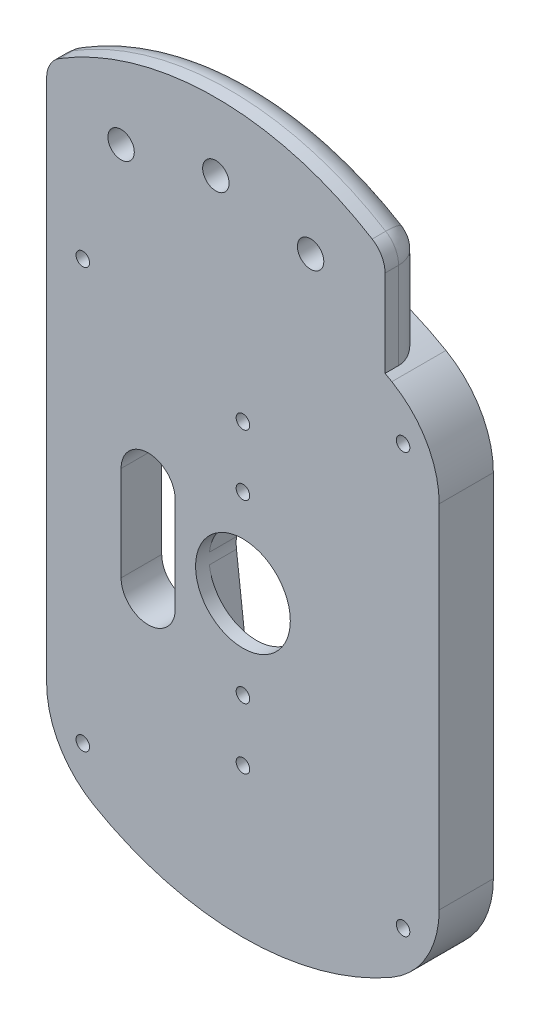
from build123d import *

# Parameters (mm, degrees)
EXTRUDE_1_DEPTH         = 6
SKETCH_1_3_R            = 1.0000000000000007
SKETCH_1_3_R_2          = 1.0000000000000009
EXTRUDE_2_DEPTH         = 2
SKETCH_1_4_R            = 1.0000000000000024
SKETCH_1_4_R_2          = 1.0000000000000022
SKETCH_1_4_R_3          = 0.9999999999999966
SKETCH_1_4_R_4          = 1.0000000000000009
EXTRUDE_3_DEPTH         = 8
CUT_EXTRUDE_1_DEPTH     = 54.0377224247045
EXTRUDE_4_DEPTH         = 6
FILLET_2_R              = 4
HOLE_WIZARD_M3_51_D     = 3.9
HOLE_WIZARD_M3_51_DEPTH = 13.828321793
HOLE_WIZARD_M3_51_TIP   = 1.1716782071037426


with BuildPart() as part:
    # Эскиз1 → Бобышка-Вытянуть1 (new body)
    with BuildSketch(Plane.XY):
        with BuildLine():
            Line((25.000000000000007, -25.98076211353316), (25.000000000000007, 25.980762113533153))
            ThreePointArc((25.000000000000007, 25.980762113533153), (24.981739705342804, 26.584808845817278), (24.927025509043382, 27.186649563837758))
            ThreePointArc((24.927025509043485, 27.18664956383775), (20.196152422706675, 28.98076211353309), (21.007841920590277, 33.974874663228555))
            ThreePointArc((21.007841920590295, 33.97487466322859), (20.513989667902422, 34.32317890618177), (20.000000000000014, 34.64101615137754))
            ThreePointArc((20.000000000000014, 34.64101615137754), (0, 40.00000000000001), (-20.000000000000018, 34.64101615137754))
            ThreePointArc((-20.000000000000014, 34.64101615137754), (-20.513989667902425, 34.32317890618177), (-21.0078419205903, 33.97487466322859))
            ThreePointArc((-21.00784192059028, 33.97487466322856), (-20.01267617924998, 32.62246116192532), (-19.660254037844396, 30.98076211353315))
            ThreePointArc((-19.660254037844396, 30.98076211353315), (-21.322208474216062, 27.735220102959588), (-24.92702550904333, 27.186649563837697))
            ThreePointArc((-24.92702550904339, 27.186649563837694), (-24.981739705342804, 26.584808845817246), (-25.000000000000007, 25.980762113533153))
            Line((-25.000000000000007, 25.980762113533153), (-25.000000000000007, -25.98076211353316))
            ThreePointArc((-25.000000000000007, -25.98076211353316), (-24.981739705342804, -26.584808845817253), (-24.92702550904339, -27.1866495638377))
            ThreePointArc((-24.927025509043325, -27.186649563837705), (-21.322208474216055, -27.735220102959595), (-19.66025403784439, -30.980762113533157))
            ThreePointArc((-19.66025403784439, -30.980762113533157), (-20.012676179249972, -32.62246116192533), (-21.007841920590273, -33.97487466322856))
            ThreePointArc((-21.007841920590288, -33.9748746632286), (-20.51398966790242, -34.32317890618177), (-20.00000000000001, -34.64101615137754))
            ThreePointArc((-20.00000000000001, -34.64101615137754), (8.9e-16, -40), (20.000000000000014, -34.64101615137754))
            ThreePointArc((20.00000000000001, -34.64101615137754), (20.51398966790242, -34.32317890618177), (21.007841920590288, -33.9748746632286))
            ThreePointArc((21.007841920590277, -33.97487466322857), (20.19615242270667, -28.980762113533096), (24.92702550904349, -27.18664956383776))
            ThreePointArc((24.927025509043382, -27.186649563837765), (24.981739705342804, -26.584808845817285), (25.000000000000007, -25.98076211353316))
        make_face()
        with BuildLine():
            ThreePointArc((-6.953246230078051, -0.8076923076923074), (-6.9999999999999964, -8e-17), (-6.953246230078052, 0.8076923076923072))
            Line((-6.953246230078053, 0.8076923076923073), (-3.9732835600445995, 26.46153846153846))
            ThreePointArc((-3.9732835600445995, 26.46153846153846), (1.61e-15, 30), (3.973283560044602, 26.46153846153846))
            Line((3.973283560044602, 26.46153846153846), (6.9532462300780535, 0.8076923076923066))
            ThreePointArc((6.9532462300780535, 0.8076923076923077), (6.988301782641701, 0.4045221807599798), (6.999999999999997, 0))
            ThreePointArc((6.999999999999997, 0), (6.988301782641701, -0.40452218075998), (6.9532462300780535, -0.8076923076923077))
            Line((6.9532462300780535, -0.8076923076923066), (3.973283560044602, -26.46153846153846))
            ThreePointArc((3.973283560044602, -26.46153846153846), (7.8e-16, -29.999999999999996), (-3.9732835600445995, -26.46153846153846))
            Line((-3.9732835600445995, -26.46153846153846), (-6.953246230078053, -0.8076923076923073))
        make_face(mode=Mode.SUBTRACT)
    extrude(amount=EXTRUDE_1_DEPTH)

    # Эскиз1<3> → Бобышка-Вытянуть2 (add)
    # profile 1 of 2: a face of its own
    with BuildSketch(Plane.XY):
        with BuildLine():
            Line((-3.9732835600445995, 26.46153846153846), (-6.953246230078053, 0.8076923076923073))
            ThreePointArc((-6.953246230078054, 0.8076923076923096), (1.98e-15, 7.000000000000001), (6.953246230078055, 0.8076923076923079))
            Line((6.9532462300780535, 0.8076923076923066), (3.973283560044602, 26.46153846153846))
            ThreePointArc((3.973283560044602, 26.46153846153846), (1.61e-15, 30), (-3.9732835600445995, 26.46153846153846))
        make_face()
        with Locations((0, 13)):
            Circle(SKETCH_1_3_R, mode=Mode.SUBTRACT)
        with Locations((0, 22)):
            Circle(SKETCH_1_3_R_2, mode=Mode.SUBTRACT)
    # profile 2 of 2: a face of its own
    with BuildSketch(Plane.XY):
        with BuildLine():
            ThreePointArc((6.953246230078054, -0.8076923076923105), (-1.29e-15, -7.000000000000001), (-6.953246230078055, -0.8076923076923079))
            Line((-6.953246230078053, -0.8076923076923073), (-3.9732835600445995, -26.46153846153846))
            ThreePointArc((-3.9732835600445995, -26.46153846153846), (7.8e-16, -29.999999999999996), (3.973283560044602, -26.46153846153846))
            Line((3.973283560044602, -26.46153846153846), (6.9532462300780535, -0.8076923076923066))
        make_face()
        with Locations((0, -22)):
            Circle(SKETCH_1_3_R_2, mode=Mode.SUBTRACT)
        with Locations((0, -13)):
            Circle(SKETCH_1_3_R, mode=Mode.SUBTRACT)
    extrude(amount=EXTRUDE_2_DEPTH)

    # Эскиз1<4> → Бобышка-Вытянуть3 (add)
    with BuildSketch(Plane.XY):
        with BuildLine():
            ThreePointArc((29.000000000000007, 25.980762113533153), (27.124355652982153, 32.98076211353315), (22.000000000000014, 38.10511776651529))
            ThreePointArc((22.000000000000014, 38.10511776651529), (-1.78e-15, 44), (-22.00000000000002, 38.10511776651529))
            ThreePointArc((-22.000000000000018, 38.10511776651529), (-27.124355652982153, 32.980762113533146), (-29.000000000000007, 25.98076211353315))
            Line((-29.000000000000007, 25.980762113533153), (-29.000000000000007, -25.98076211353316))
            ThreePointArc((-29.000000000000007, -25.98076211353316), (-27.124355652982146, -32.98076211353315), (-22.00000000000002, -38.10511776651529))
            ThreePointArc((-22.000000000000025, -38.10511776651529), (-6.22e-15, -44.00000000000001), (22.000000000000014, -38.1051177665153))
            ThreePointArc((22.000000000000014, -38.1051177665153), (27.124355652982153, -32.98076211353316), (29.00000000000001, -25.98076211353316))
            Line((29.000000000000007, -25.98076211353316), (29.00000000000001, 25.980762113533153))
        make_face()
        with BuildLine():
            ThreePointArc((24.927025509043382, 27.186649563837758), (24.981739705342804, 26.584808845817278), (25.000000000000007, 25.980762113533153))
            Line((25.000000000000007, 25.980762113533153), (25.000000000000007, -25.98076211353316))
            ThreePointArc((25.000000000000007, -25.98076211353316), (24.981739705342804, -26.584808845817285), (24.927025509043382, -27.186649563837765))
            ThreePointArc((24.92702550904349, -27.18664956383776), (20.19615242270667, -28.980762113533096), (21.007841920590277, -33.97487466322857))
            ThreePointArc((21.007841920590288, -33.9748746632286), (20.51398966790242, -34.32317890618177), (20.00000000000001, -34.64101615137754))
            ThreePointArc((20.000000000000014, -34.64101615137754), (8.9e-16, -40), (-20.00000000000001, -34.64101615137754))
            ThreePointArc((-20.00000000000001, -34.64101615137754), (-20.51398966790242, -34.32317890618177), (-21.007841920590288, -33.9748746632286))
            ThreePointArc((-21.00784192059027, -33.97487466322856), (-20.19615242270663, -28.980762113533167), (-24.927025509043325, -27.186649563837705))
            ThreePointArc((-24.92702550904339, -27.1866495638377), (-24.981739705342804, -26.584808845817253), (-25.000000000000007, -25.98076211353316))
            Line((-25.000000000000007, -25.98076211353316), (-25.000000000000007, 25.980762113533153))
            ThreePointArc((-25.000000000000007, 25.980762113533153), (-24.981739705342804, 26.584808845817246), (-24.92702550904339, 27.186649563837694))
            ThreePointArc((-24.92702550904333, 27.186649563837697), (-20.196152422706632, 28.980762113533164), (-21.00784192059028, 33.97487466322856))
            ThreePointArc((-21.0078419205903, 33.97487466322859), (-20.513989667902425, 34.32317890618177), (-20.000000000000014, 34.64101615137754))
            ThreePointArc((-20.000000000000018, 34.64101615137754), (0, 40.00000000000001), (20.000000000000014, 34.64101615137754))
            ThreePointArc((20.000000000000014, 34.64101615137754), (20.513989667902422, 34.32317890618177), (21.007841920590295, 33.97487466322859))
            ThreePointArc((21.007841920590277, 33.974874663228555), (20.196152422706675, 28.98076211353309), (24.927025509043485, 27.18664956383775))
        make_face(mode=Mode.SUBTRACT)
        with Locations((23.6602540378444, 30.98076211353315)):
            Circle(SKETCH_1_4_R, mode=Mode.SUBTRACT)
        with Locations((23.660254037844393, -30.980762113533157)):
            Circle(SKETCH_1_4_R_2, mode=Mode.SUBTRACT)
        with Locations((-23.660254037844393, 30.98076211353315)):
            Circle(SKETCH_1_4_R_3, mode=Mode.SUBTRACT)
        with Locations((-23.660254037844396, -30.98076211353316)):
            Circle(SKETCH_1_4_R_4, mode=Mode.SUBTRACT)
    extrude(amount=EXTRUDE_3_DEPTH)

    # Эскиз2 → Вырез-Вытянуть1 (cut, through all)
    with BuildSketch(Plane.XY.offset(6)):
        with BuildLine():
            Line((-17.998748741118916, -6.999248963798453), (-17.998748741118916, 7.000751036201546))
            ThreePointArc((-17.998748741118916, 7.000751036201546), (-13.99874874111892, 11.00075103620155), (-9.998748741118916, 7.0007510362015495))
            Line((-9.998748741118916, 7.0007510362015495), (-9.998748741118915, -6.999248963798453))
            ThreePointArc((-9.998748741118915, -6.999248963798453), (-13.998748741118916, -10.999248963798454), (-17.998748741118916, -6.999248963798453))
        make_face()
    extrude(amount=-CUT_EXTRUDE_1_DEPTH, mode=Mode.SUBTRACT)

    # Эскиз1<5> → Бобышка-Вытянуть4 (add)
    with BuildSketch(Plane.XY):
        with BuildLine():
            ThreePointArc((-22.00000000000002, 38.10511776651529), (-0.5730893375891295, 43.99626766682762), (21, 38.66522985836241))
            Line((20.999999999999996, 38.665229858362416), (20.999999999999986, 53.66522985836241))
            ThreePointArc((20.99999999999999, 53.665229858362416), (-4.000000000000013, 61.45749587789907), (-29.00000000000001, 53.665229858362416))
            Line((-29.000000000000007, 53.66522985836241), (-29.000000000000007, 25.980762113533153))
            ThreePointArc((-29.000000000000007, 25.980762113533153), (-28.522961473136743, 29.604229099178195), (-27.124355286277215, 32.98076274868469))
            ThreePointArc((-27.124355286277215, 32.98076274868469), (-24.89949467731214, 35.880257309444346), (-22.000000000000014, 38.10511776651529))
        make_face()
    extrude(amount=EXTRUDE_4_DEPTH)

    # Скругление2
    fillet_2_edges = [part.edges().sort_by_distance(p)[0] for p in [
        (-4.000000000000006, 61.45749587789908, 6),
        (20.999999999999993, 46.16522985836241, 6),
        (20.99999999999999, 53.665229858362416, 3),
        (-29.000000000000007, 53.665229858362416, 3),
        (-29.000000000000007, 39.822995985947784, 6),
    ]]
    fillet(fillet_2_edges, radius=FILLET_2_R)

    # Отверстие с зазором M3.51
    with Locations(Plane.XY.offset(6)):
        with Locations((-18, 48.441362648), (-4, 51.457495878), (10, 48.441362648)):
            Hole(HOLE_WIZARD_M3_51_D / 2, depth=HOLE_WIZARD_M3_51_DEPTH)
            with Locations((0, 0, -(HOLE_WIZARD_M3_51_DEPTH + HOLE_WIZARD_M3_51_TIP / 2))):  # 118° drill point
                Cone(0, HOLE_WIZARD_M3_51_D / 2, HOLE_WIZARD_M3_51_TIP, mode=Mode.SUBTRACT)


with BuildPart() as body_2:
    # Зеркальное отражение1: mirrored copy
    add(part.part.mirror(Plane.XY))


solid = body_2.part
